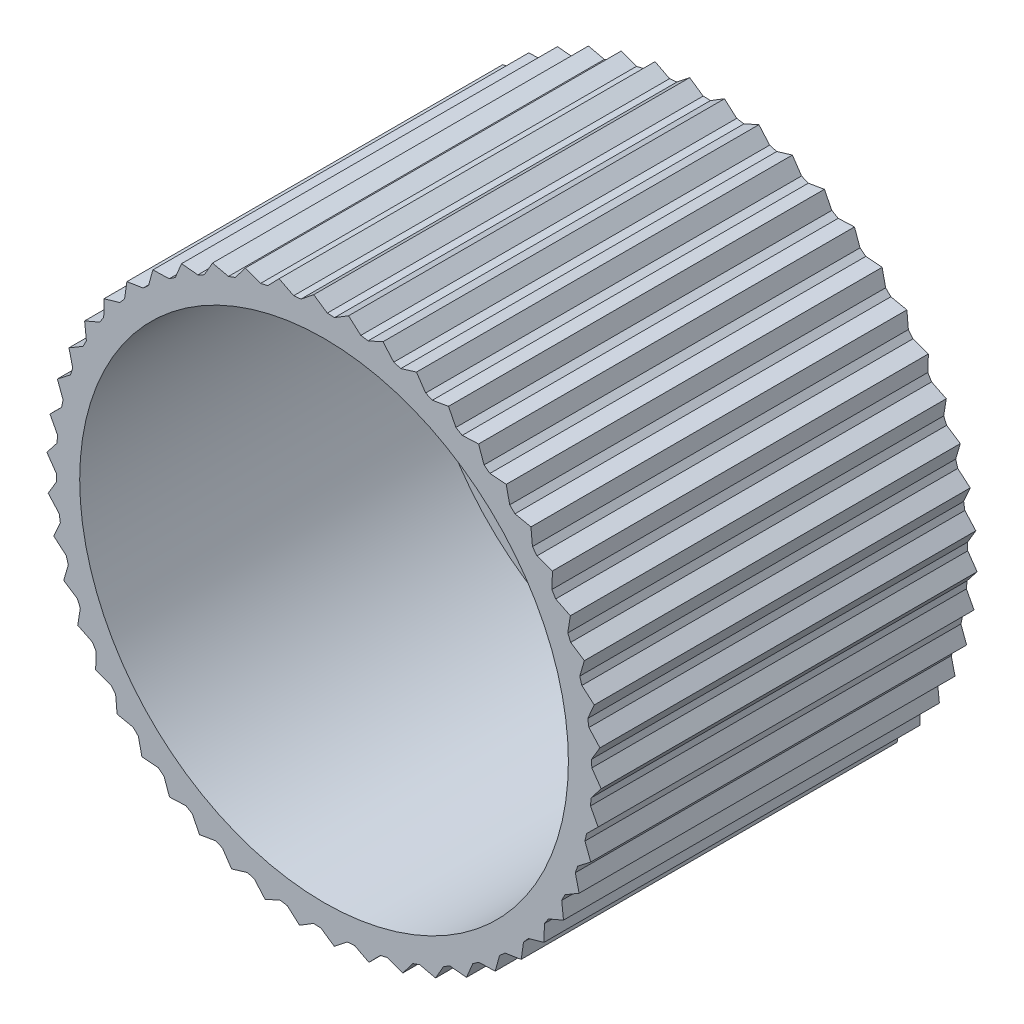
from build123d import *

# Parameters (mm, degrees)
ESQUISSE1_R             = 1
BOSS_EXTRU_1_DEPTH      = 20
ESQUISSE2_R             = 13
ESQUISSE2_R_2           = 3
ENL_V_MAT_EXTRU_1_DEPTH = 18
ESQUISSE3_R             = 3
ENL_V_MAT_EXTRU_2_DEPTH = 15


with BuildPart() as part:
    # Esquisse1 → Boss.-Extru.1 (new body)
    with BuildSketch(Plane.XY):
        Polygon((12.738384473, -7.436132127), (12.644521362, -6.571040977), (12.819850246, -6.222052689), (13.569932991, -5.780953088), (13.368385348, -4.934447607), (13.498591881, -4.56623666), (14.18747556, -4.034604965), (13.881421911, -3.22003505), (13.964452658, -2.838408351), (14.581273164, -2.224628712), (14.175540158, -1.454840618), (14.210085674, -1.065816647), (14.74511538, -0.379568735), (14.246101669, 0.333297521), (14.231617151, 0.723583623), (14.676418318, 1.471477268), (14.091993646, 2.116179358), (14.028707524, 2.501572546), (14.376265372, 3.299317195), (13.715646465, 3.865687783), (13.604556799, 4.240110176), (13.849390133, 5.075124919), (13.122995347, 5.554232002), (12.965854086, 5.911778736), (13.104101738, 6.770894891), (12.323386752, 7.155182664), (12.122672109, 7.490215013), (12.152153831, 8.359883807), (11.329430986, 8.643291822), (11.088308351, 8.950526125), (11.008559199, 9.81703236), (10.156803327, 9.995091104), (9.879075346, 10.269682094), (9.691353012, 11.119360449), (8.823996811, 11.189261829), (8.514043422, 11.426879041), (8.221308398, 12.246329582), (7.352030594, 12.206971211), (7.014739946, 12.403867279), (6.62160884, 13.180166781), (5.764118463, 13.032169365), (5.404809832, 13.185239121), (4.917482555, 13.906144876), (4.08530274, 13.651842422), (3.709642638, 13.758671865), (3.135804633, 14.41281476), (2.342059353, 14.05621777), (1.955972163, 14.115122135), (1.304673198, 14.692185945), (0.561880291, 14.238918166), (0.171454839, 14.248968497), (-0.547033712, 14.739852581), (-1.227159959, 14.197062317), (-1.61576643, 14.158100114), (-2.390113575, 14.555062937), (-2.996847164, 13.931310314), (-3.377506098, 13.843950035), (-4.195499918, 14.140731255), (-4.719272298, 13.445853226), (-5.085980477, 13.311472593), (-5.934720721, 13.503391795), (-6.367271689, 12.748347), (-6.714245905, 12.569065277), (-7.580347433, 12.653095779), (-7.914855402, 11.849791726), (-8.236623665, 11.628436292), (-9.106427538, 11.603252884), (-9.337617118, 10.764358158), (-9.629104949, 10.504419922), (-10.488893841, 10.37041976), (-10.613119033, 9.509164232), (-10.869729496, 9.214742573), (-11.705944022, 8.974038921), (-11.721245721, 8.104005105), (-11.938931915, 7.77974323), (-12.738384473, 7.436132127), (-12.644521362, 6.571040977), (-12.819850246, 6.222052689), (-13.569932991, 5.780953088), (-13.368385348, 4.934447607), (-13.498591881, 4.56623666), (-14.18747556, 4.034604965), (-13.881421911, 3.22003505), (-13.964452658, 2.838408351), (-14.581273164, 2.224628712), (-14.175540158, 1.454840618), (-14.210085674, 1.065816647), (-14.74511538, 0.379568735), (-14.246101669, -0.333297521), (-14.231617151, -0.723583623), (-14.676418318, -1.471477268), (-14.091993646, -2.116179358), (-14.028707524, -2.501572546), (-14.376265372, -3.299317195), (-13.715646465, -3.865687783), (-13.604556799, -4.240110176), (-13.849390133, -5.075124919), (-13.122995347, -5.554232002), (-12.965854086, -5.911778736), (-13.104101738, -6.770894891), (-12.323386752, -7.155182664), (-12.122672109, -7.490215013), (-12.152153831, -8.359883807), (-11.329430986, -8.643291822), (-11.088308351, -8.950526125), (-11.008559199, -9.81703236), (-10.156803327, -9.995091104), (-9.879075346, -10.269682094), (-9.691353012, -11.119360449), (-8.823996811, -11.189261829), (-8.514043422, -11.426879041), (-8.221308398, -12.246329582), (-7.352030594, -12.206971211), (-7.014739946, -12.403867279), (-6.62160884, -13.180166781), (-5.764118463, -13.032169365), (-5.404809832, -13.185239121), (-4.917482555, -13.906144876), (-4.08530274, -13.651842422), (-3.709642638, -13.758671865), (-3.135804633, -14.41281476), (-2.342059353, -14.05621777), (-1.955972163, -14.115122135), (-1.304673198, -14.692185945), (-0.561880291, -14.238918166), (-0.171454839, -14.248968497), (0.547033712, -14.739852581), (1.227159959, -14.197062317), (1.61576643, -14.158100114), (2.390113575, -14.555062937), (2.996847164, -13.931310314), (3.377506098, -13.843950035), (4.195499918, -14.140731255), (4.719272298, -13.445853226), (5.085980477, -13.311472593), (5.934720721, -13.503391795), (6.367271689, -12.748347), (6.714245905, -12.569065277), (7.580347433, -12.653095779), (7.914855402, -11.849791726), (8.236623665, -11.628436292), (9.106427538, -11.603252884), (9.337617118, -10.764358158), (9.629104949, -10.504419922), (10.488893841, -10.37041976), (10.613119033, -9.509164232), (10.869729496, -9.214742573), (11.705944022, -8.974038921), (11.721245721, -8.104005105), (11.938931915, -7.77974323), align=None)
        Circle(ESQUISSE1_R, mode=Mode.SUBTRACT)
    extrude(amount=BOSS_EXTRU_1_DEPTH)

    # Esquisse2 → Enlèv. mat.-Extru.1 (cut)
    with BuildSketch(Plane.XY.offset(20)):
        Circle(ESQUISSE2_R)
        Circle(ESQUISSE2_R_2, mode=Mode.SUBTRACT)
    extrude(amount=-ENL_V_MAT_EXTRU_1_DEPTH, mode=Mode.SUBTRACT)

    # Esquisse3 → Enlèv. mat.-Extru.2 (cut)
    with BuildSketch(Plane.XY.offset(20)):
        Circle(ESQUISSE3_R)
    extrude(amount=-ENL_V_MAT_EXTRU_2_DEPTH, mode=Mode.SUBTRACT)


solid = part.part
